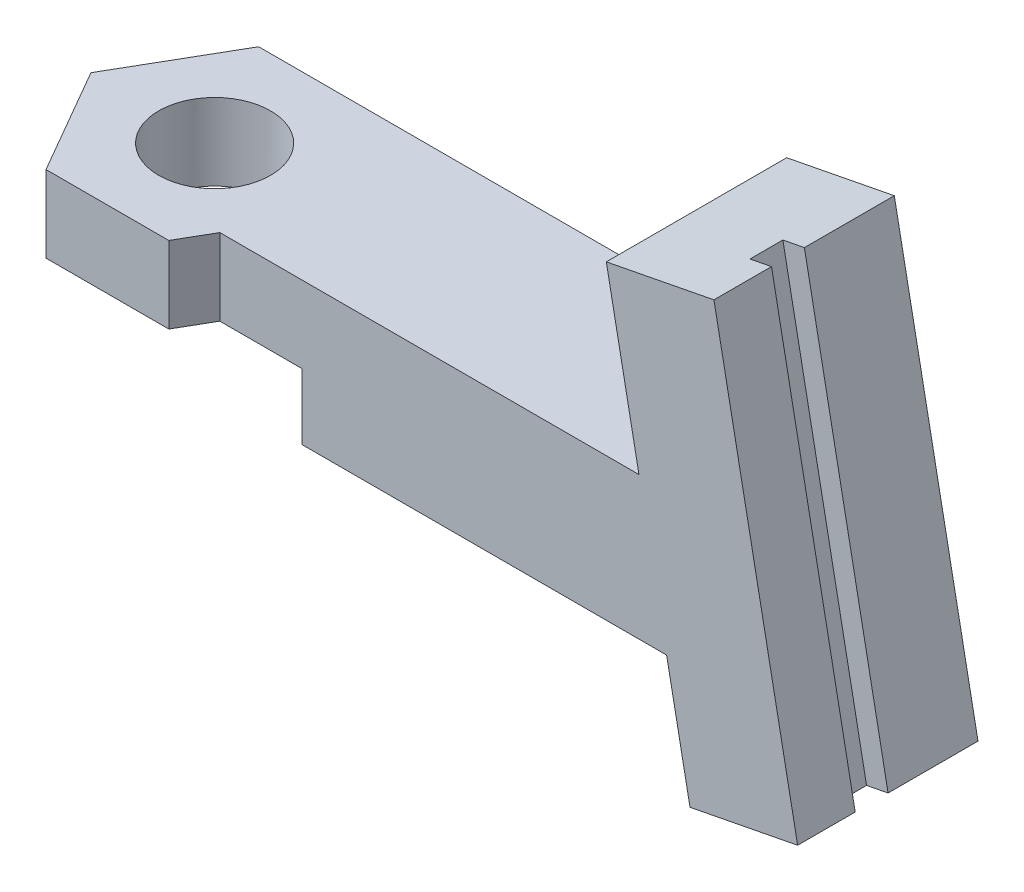
from build123d import *

# Parameters (mm, degrees)
SKETCH1_W                       = 25
SKETCH1_H                       = 6.75
BOSS_EXTRUDE1_DEPTH             = 6.5
BOSS_EXTRUDE3_REACH             = 5.375
BOSS_EXTRUDE3_DIRECTION_2_REACH = 5.375
SKETCH4_W                       = 1
SKETCH4_H                       = 1.5
CUT_EXTRUDE1_DEPTH              = 23
BOSS_EXTRUDE4_DEPTH             = 6.5
SKETCH6_R                       = 2.55
CUT_EXTRUDE2_DEPTH              = 10
BOSS_EXTRUDE5_DEPTH             = 1.475
CUT_EXTRUDE3_DEPTH              = 3


with BuildPart() as part:
    # Sketch1 → Boss-Extrude1 (new body)
    with BuildSketch(Plane(origin=(0, 0, 0), x_dir=(1, 0, 0), z_dir=(0, 1, 0))):
        with Locations((12.5, -3.375)):
            Rectangle(SKETCH1_W, SKETCH1_H)
    extrude(amount=BOSS_EXTRUDE1_DEPTH)

    # Boss-Extrude3: up to this face of the body (flat: up to its plane)
    boss_extrude3_end = Plane(part.part.faces().sort_by_distance((12.5, 3.25, 0))[0])
    # Sketch3 → Boss-Extrude3 (add, up to the picked face)
    with BuildSketch(Plane.XY.offset(3.375), mode=Mode.PRIVATE) as boss_extrude3_sk1:
        Polygon((21.275684175, 14.155521181), (26.183820092, 15.109566157), (30, -4.522977512), (25.091864083, -5.477022488), align=None)
    boss_extrude3_tool1 = split(extrude(boss_extrude3_sk1.sketch, amount=-BOSS_EXTRUDE3_REACH, mode=Mode.PRIVATE), bisect_by=boss_extrude3_end, keep=Keep.BOTH, mode=Mode.PRIVATE)
    add(boss_extrude3_tool1.solids().sort_by_distance((25.637842, 4.816272, 3.375))[0])

    # Boss-Extrude3 direction 2: up to this face of the body (flat: up to its plane)
    boss_extrude3_direction_2_end = Plane(part.part.faces().sort_by_distance((12.5, 3.25, 6.75))[0])
    # Sketch3 → Boss-Extrude3 direction 2 (add, up to the picked face)
    with BuildSketch(Plane.XY.offset(3.375), mode=Mode.PRIVATE) as boss_extrude3_direction_2_sk1:
        Polygon((21.275684175, 14.155521181), (26.183820092, 15.109566157), (30, -4.522977512), (25.091864083, -5.477022488), align=None)
    boss_extrude3_direction_2_tool1 = split(extrude(boss_extrude3_direction_2_sk1.sketch, amount=BOSS_EXTRUDE3_DIRECTION_2_REACH, mode=Mode.PRIVATE), bisect_by=boss_extrude3_direction_2_end, keep=Keep.BOTH, mode=Mode.PRIVATE)
    add(boss_extrude3_direction_2_tool1.solids().sort_by_distance((25.637842, 4.816272, 3.375))[0])

    # Sketch4 → Cut-Extrude1 (cut)
    with BuildSketch(Plane(origin=(-1.876769127, 9.65514015, 0), x_dir=(0.981627183, 0.190808995, 0), z_dir=(-0.190808995, 0.981627183, 0))):
        with Locations((28.085790708, -3.375)):
            Rectangle(SKETCH4_W, SKETCH4_H)
    extrude(amount=-CUT_EXTRUDE1_DEPTH, mode=Mode.SUBTRACT)

    # Sketch5 → Boss-Extrude4 (add)
    with BuildSketch(Plane(origin=(0, 6.5, 0), x_dir=(1, 0, 0), z_dir=(0, 1, 0))):
        Polygon((-5.600297611, -3.375), (-2.800148806, -8.225), (2.800148806, -8.225), (5.600297611, -3.375), (2.800148806, 1.475), (-2.800148806, 1.475), align=None)
    extrude(amount=-BOSS_EXTRUDE4_DEPTH)

    # Sketch6 → Cut-Extrude2 (cut)
    with BuildSketch(Plane(origin=(0, 6.5, 0), x_dir=(1, 0, 0), z_dir=(0, 1, 0))):
        with Locations((0, -3.335615973)):
            Circle(SKETCH6_R)
    extrude(amount=-CUT_EXTRUDE2_DEPTH, mode=Mode.SUBTRACT)

    # Sketch7 → Boss-Extrude5 (add)
    with BuildSketch(Plane(origin=(0, 0, -1.475), x_dir=(-1, 0, 0), z_dir=(0, 0, -1))):
        Polygon((-2.800148806, 0), (-24.027238758, 0), (-25.091864083, -5.477022488), (-30, -4.522977512), (-26.183820092, 15.109566157), (-21.275684175, 14.155521181), (-22.763766749, 6.5), (-2.800148806, 6.5), align=None)
    extrude(amount=-BOSS_EXTRUDE5_DEPTH)

    # Sketch8 → Cut-Extrude3 (cut)
    with BuildSketch(Plane(origin=(0, 0, 0), x_dir=(-1, 0, 0), z_dir=(0, -1, 0))):
        Polygon((-4.67653718, -11.475), (4.67653718, -11.475), (9.353074361, -3.375), (4.67653718, 4.725), (-4.67653718, 4.725), (-9.353074361, -3.375), align=None)
    extrude(amount=-CUT_EXTRUDE3_DEPTH, mode=Mode.SUBTRACT)


solid = part.part
